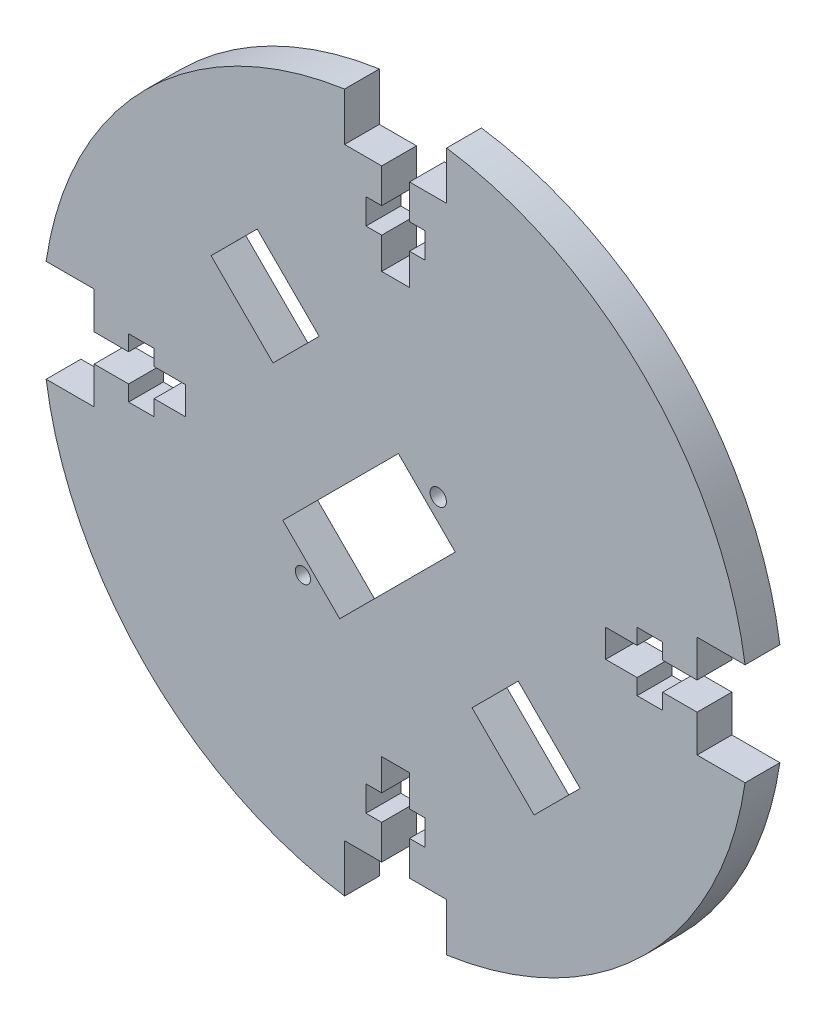
from build123d import *

# Parameters (mm, degrees)
SKETCH3_R           = 1.089052178
SKETCH3_R_2         = 1.175054292
BOSS_EXTRUDE5_DEPTH = 5


with BuildPart() as part:
    # Sketch3 → Boss-Extrude5 (new body)
    with BuildSketch(Plane.XY):
        with BuildLine():
            Line((81.038403504, 109.892462561), (81.038403504, 102.992462561))
            Line((81.038403504, 102.992462561), (75.701022894, 102.992462561))
            Line((75.701022894, 102.992462561), (75.701022894, 98.038427684))
            Line((75.701022894, 98.038427684), (77.959022894, 98.038427684))
            Line((77.959022894, 98.038427684), (77.959022894, 94.370627684))
            Line((77.959022894, 94.370627684), (75.701022894, 94.370627684))
            Line((75.701022894, 94.370627684), (75.701022894, 89.854027684))
            Line((75.701022894, 89.854027684), (71.701022894, 89.854027684))
            Line((71.701022894, 89.854027684), (71.701022894, 94.370627684))
            Line((71.701022894, 94.370627684), (69.443022894, 94.370627684))
            Line((69.443022894, 94.370627684), (69.443022894, 98.038427684))
            Line((69.443022894, 98.038427684), (71.701022894, 98.038427684))
            Line((71.701022894, 98.038427684), (71.701022894, 102.992462561))
            Line((71.701022894, 102.992462561), (66.363642284, 102.992462561))
            Line((66.363642284, 102.992462561), (66.363642284, 109.892462561))
            ThreePointArc((66.363642284, 109.892462561), (37.802245989, 95.555722027), (23.465505456, 66.994325733))
            Line((23.465505456, 66.994325733), (30.365505456, 66.994325733))
            Line((30.365505456, 66.994325733), (30.365505456, 61.656945123))
            Line((30.365505456, 61.656945123), (35.319540332, 61.656945123))
            Line((35.319540332, 61.656945123), (35.319540332, 63.914945123))
            Line((35.319540332, 63.914945123), (38.987340332, 63.914945123))
            Line((38.987340332, 63.914945123), (38.987340332, 61.656945123))
            Line((38.987340332, 61.656945123), (43.503940332, 61.656945123))
            Line((43.503940332, 61.656945123), (43.503940332, 57.656945123))
            Line((43.503940332, 57.656945123), (38.987340332, 57.656945123))
            Line((38.987340332, 57.656945123), (38.987340332, 55.398945123))
            Line((38.987340332, 55.398945123), (35.319540332, 55.398945123))
            Line((35.319540332, 55.398945123), (35.319540332, 57.656945123))
            Line((35.319540332, 57.656945123), (30.365505456, 57.656945123))
            Line((30.365505456, 57.656945123), (30.365505456, 52.319564513))
            Line((30.365505456, 52.319564513), (23.465505456, 52.319564513))
            ThreePointArc((23.465505456, 52.319564513), (37.802245989, 23.758168218), (66.363642284, 9.421427684))
            Line((66.363642284, 9.421427684), (66.363642284, 16.321427684))
            Line((66.363642284, 16.321427684), (71.701022894, 16.321427684))
            Line((71.701022894, 16.321427684), (71.701022894, 21.275462561))
            Line((71.701022894, 21.275462561), (69.443022894, 21.275462561))
            Line((69.443022894, 21.275462561), (69.443022894, 24.943262561))
            Line((69.443022894, 24.943262561), (71.701022894, 24.943262561))
            Line((71.701022894, 24.943262561), (71.701022894, 29.459862561))
            Line((71.701022894, 29.459862561), (75.701022894, 29.459862561))
            Line((75.701022894, 29.459862561), (75.701022894, 24.943262561))
            Line((75.701022894, 24.943262561), (77.959022894, 24.943262561))
            Line((77.959022894, 24.943262561), (77.959022894, 21.275462561))
            Line((77.959022894, 21.275462561), (75.701022894, 21.275462561))
            Line((75.701022894, 21.275462561), (75.701022894, 16.321427684))
            Line((75.701022894, 16.321427684), (81.038403504, 16.321427684))
            Line((81.038403504, 16.321427684), (81.038403504, 9.421427684))
            ThreePointArc((81.038403504, 9.421427684), (109.599799799, 23.758168218), (123.936540332, 52.319564513))
            Line((123.936540332, 52.319564513), (117.036540332, 52.319564513))
            Line((117.036540332, 52.319564513), (117.036540332, 57.656945123))
            Line((117.036540332, 57.656945123), (112.082505456, 57.656945123))
            Line((112.082505456, 57.656945123), (112.082505456, 55.398945123))
            Line((112.082505456, 55.398945123), (108.414705456, 55.398945123))
            Line((108.414705456, 55.398945123), (108.414705456, 57.656945123))
            Line((108.414705456, 57.656945123), (103.898105456, 57.656945123))
            Line((103.898105456, 57.656945123), (103.898105456, 61.656945123))
            Line((103.898105456, 61.656945123), (108.414705456, 61.656945123))
            Line((108.414705456, 61.656945123), (108.414705456, 63.914945123))
            Line((108.414705456, 63.914945123), (112.082505456, 63.914945123))
            Line((112.082505456, 63.914945123), (112.082505456, 61.656945123))
            Line((112.082505456, 61.656945123), (117.036540332, 61.656945123))
            Line((117.036540332, 61.656945123), (117.036540332, 66.994325733))
            Line((117.036540332, 66.994325733), (123.936540332, 66.994325733))
            ThreePointArc((123.936540332, 66.994325733), (109.599799799, 95.555722027), (81.038403504, 109.892462561))
        make_face()
        with Locations((60.382249582, 46.393077684)):
            Circle(SKETCH3_R, mode=Mode.SUBTRACT)
        Polygon((65.663040298, 43.594110186), (57.487806829, 51.769189843), (74.099869727, 68.381565292), (82.275103197, 60.206485634), align=None, mode=Mode.SUBTRACT)
        Polygon((93.597305456, 33.128564513), (84.692315031, 42.034629122), (91.325115031, 48.666629122), (100.230105456, 39.760564513), align=None, mode=Mode.SUBTRACT)
        Polygon((56.078706893, 70.64823726), (47.172642284, 79.553227684), (53.804642284, 86.186027684), (62.710706893, 77.28103726), align=None, mode=Mode.SUBTRACT)
        with Locations((79.827503135, 65.838697094)):
            Circle(SKETCH3_R_2, mode=Mode.SUBTRACT)
    extrude(amount=BOSS_EXTRUDE5_DEPTH)


solid = part.part
